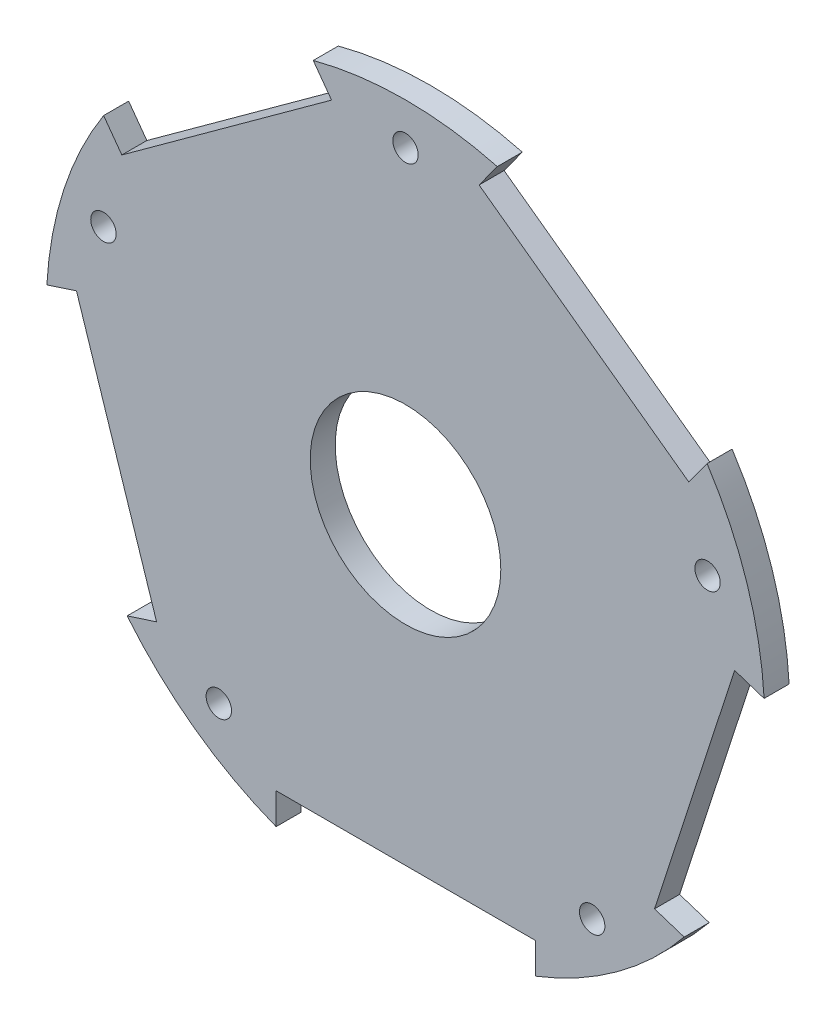
from build123d import *

# Parameters (mm, degrees)
SKETCH1_R           = 19.05
BOSS_EXTRUDE2_DEPTH = 5.0038
SKETCH2_R           = 2.54
CUT_EXTRUDE1_DEPTH  = 7.5438
CIRPATTERN1_COUNT   = 5


with BuildPart() as part:
    # Sketch1 → Boss-Extrude2 (new body)
    with BuildSketch(Plane.XY):
        with BuildLine():
            Line((207.237556858, -115.975983371), (165.317532277, -85.519302738))
            Line((165.317532277, -85.519302738), (168.955516395, -80.512047172))
            ThreePointArc((168.955516395, -80.512047172), (150.561502758, -78.127913016), (132.170605091, -80.535965413))
            Line((132.170605091, -80.535965413), (135.828392716, -85.570478169))
            Line((135.828392716, -85.570478169), (93.908368135, -116.027158802))
            Line((93.908368135, -116.027158802), (90.270384017, -111.019903235))
            ThreePointArc((90.270384017, -111.019903235), (82.318874884, -127.776911795), (78.925968887, -146.011823976))
            Line((78.925968887, -146.011823976), (84.844393588, -144.08881122))
            Line((84.844393588, -144.08881122), (100.856418169, -193.368755668))
            Line((100.856418169, -193.368755668), (94.970036216, -195.281357105))
            ThreePointArc((94.970036216, -195.281357105), (108.449746946, -208.0218921), (124.743713387, -216.883635212))
            Line((124.743713387, -216.883635212), (124.743713387, -210.660635212))
            Line((124.743713387, -210.660635212), (176.559713387, -210.660635212))
            Line((176.559713387, -210.660635212), (176.559713387, -216.849943473))
            ThreePointArc((176.559713387, -216.849943473), (192.842141911, -207.967018576), (206.305272979, -195.208964837))
            Line((206.305272979, -195.208964837), (200.386848278, -193.285952081))
            Line((200.386848278, -193.285952081), (216.398872859, -144.006007633))
            Line((216.398872859, -144.006007633), (222.285254812, -145.918609069))
            ThreePointArc((222.285254812, -145.918609069), (218.868638328, -127.688124568), (210.895344483, -110.941470615))
            Line((210.895344483, -110.941470615), (207.237556858, -115.975983371))
        make_face()
        with Locations((150.608180965, -149.916372011)):
            Circle(SKETCH1_R, mode=Mode.SUBTRACT)
    extrude(amount=BOSS_EXTRUDE2_DEPTH)

    # Sketch2 → Cut-Extrude1 (cut)
    with BuildSketch(Plane(origin=(0, 0, 0), x_dir=(-1, 0, 0), z_dir=(0, 0, -1))):
        with Locations((-150.608395424, -86.435544776)):
            Circle(SKETCH2_R)
    cut_extrude1 = extrude(amount=-CUT_EXTRUDE1_DEPTH, mode=Mode.SUBTRACT)

    # CirPattern1: Cut-Extrude1 ×5 about axis
    cirpattern1_axis = Axis((150.608180965, -149.916372011, 0), (0, 0, 1))
    for i in range(1, CIRPATTERN1_COUNT):
        add(cut_extrude1.rotate(cirpattern1_axis, i * 360 / CIRPATTERN1_COUNT), mode=Mode.SUBTRACT)


solid = part.part
